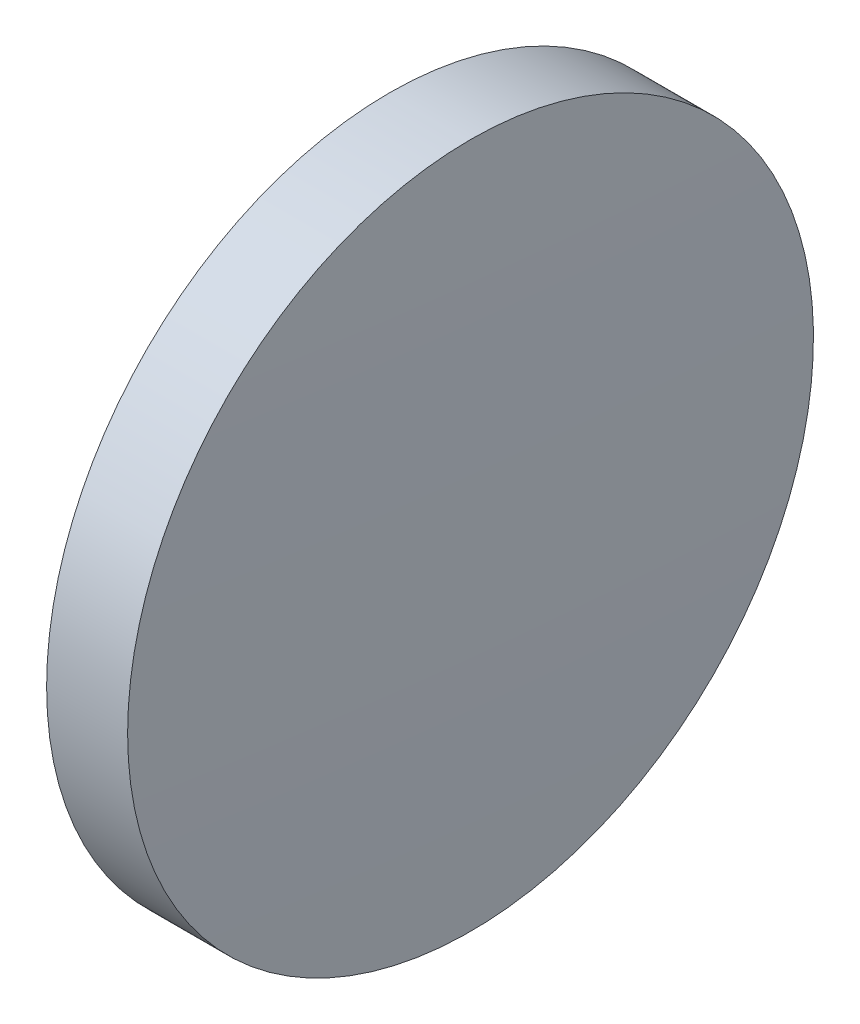
from build123d import *

# Parameters (mm, degrees)
SKETCH_1_ONE_SIDE_W = 2.999957714
SKETCH_1_ONE_SIDE_H = 12.7


with BuildPart() as part:
    # 草图1 one side → 旋转1 (revolve)
    with BuildSketch(Plane.XY):
        with Locations((86.458193775, 54.966113023)):
            Rectangle(SKETCH_1_ONE_SIDE_W, SKETCH_1_ONE_SIDE_H)
        with BuildLine():
            Line((84.783274229, 48.616113023), (84.958214918, 48.616113023))
            Line((84.958214918, 48.616113023), (84.958214918, 61.316113023))
            ThreePointArc((84.958214918, 61.316113023), (84.827011475, 54.96671544), (84.783274229, 48.616113023))
        make_face()
        with BuildLine():
            Line((87.958172632, 48.616113023), (88.133113321, 48.616113023))
            ThreePointArc((88.133113321, 48.616113023), (88.089376074, 54.96671544), (87.958172632, 61.316113023))
            Line((87.958172632, 61.316113023), (87.958172632, 48.616113023))
        make_face()
    revolve(axis=Axis((83.371981052, 48.616113023, 0), (1, 0, 0)))


solid = part.part
